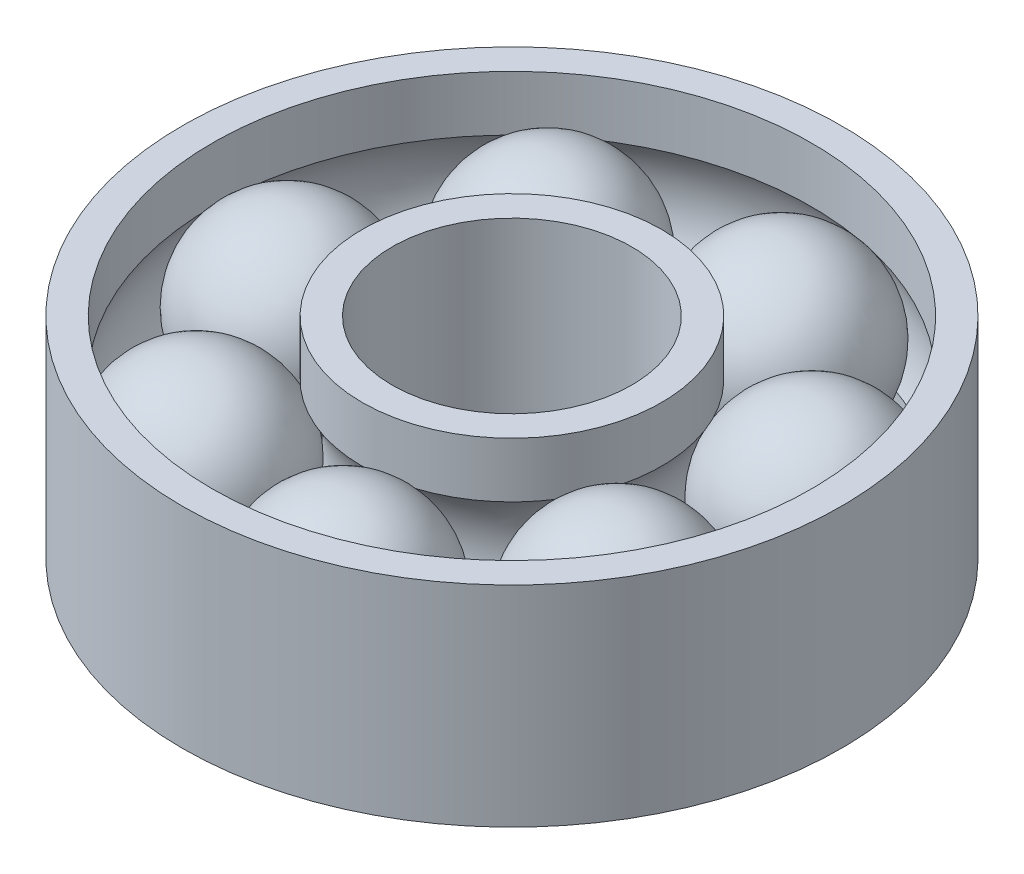
from build123d import *

# Parameters (mm, degrees)
CIRPATTERN3_COUNT = 7


with BuildPart() as part:
    # Sketch3 → ball (revolve)
    with BuildSketch(Plane.XY):
        with BuildLine():
            Line((-7.5, 4.042917623), (-7.5, -1.957082377))
            ThreePointArc((-7.5, -1.957082377), (-4.5, 1.042917623), (-7.5, 4.042917623))
        make_face()
    revolve(axis=Axis((-7.5, 4.042917623, 0), (0, -1, 0)))


with BuildPart() as body_2:
    # Sketch1 → body (revolve)
    with BuildSketch(Plane.XY):
        with BuildLine():
            Line((-4, 4.542917623), (-5, 4.542917623))
            Line((-5, 4.542917623), (-5, 2.701230018))
            ThreePointArc((-5, 2.701230018), (-4.5, 1.042917623), (-5, -0.615394772))
            Line((-5, -0.615394772), (-5, -2.457082377))
            Line((-5, -2.457082377), (-4, -2.457082377))
            Line((-4, -2.457082377), (-4, 4.542917623))
        make_face()
        with BuildLine():
            Line((-10, 4.542917623), (-11, 4.542917623))
            Line((-11, 4.542917623), (-11, -2.457082377))
            Line((-11, -2.457082377), (-10, -2.457082377))
            Line((-10, -2.457082377), (-10, -0.615394772))
            ThreePointArc((-10, -0.615394772), (-10.5, 1.042917623), (-10, 2.701230018))
            Line((-10, 2.701230018), (-10, 4.542917623))
        make_face()
    revolve(axis=Axis((0, 50, 0), (0, -1, 0)))


with BuildPart() as cirpattern3_1:
    # CirPattern3: pattern copy
    add(part.part.rotate(Axis((0, 0, 0), (0, 1, 0)), 1 * 360 / CIRPATTERN3_COUNT))


with BuildPart() as cirpattern3_2:
    # CirPattern3: pattern copy
    add(part.part.rotate(Axis((0, 0, 0), (0, 1, 0)), 2 * 360 / CIRPATTERN3_COUNT))


with BuildPart() as cirpattern3_3:
    # CirPattern3: pattern copy
    add(part.part.rotate(Axis((0, 0, 0), (0, 1, 0)), 3 * 360 / CIRPATTERN3_COUNT))


with BuildPart() as cirpattern3_4:
    # CirPattern3: pattern copy
    add(part.part.rotate(Axis((0, 0, 0), (0, 1, 0)), 4 * 360 / CIRPATTERN3_COUNT))


with BuildPart() as cirpattern3_5:
    # CirPattern3: pattern copy
    add(part.part.rotate(Axis((0, 0, 0), (0, 1, 0)), 5 * 360 / CIRPATTERN3_COUNT))


with BuildPart() as cirpattern3_6:
    # CirPattern3: pattern copy
    add(part.part.rotate(Axis((0, 0, 0), (0, 1, 0)), 6 * 360 / CIRPATTERN3_COUNT))


solid = Compound([part.part, body_2.part, cirpattern3_1.part, cirpattern3_2.part, cirpattern3_3.part, cirpattern3_4.part, cirpattern3_5.part, cirpattern3_6.part])
